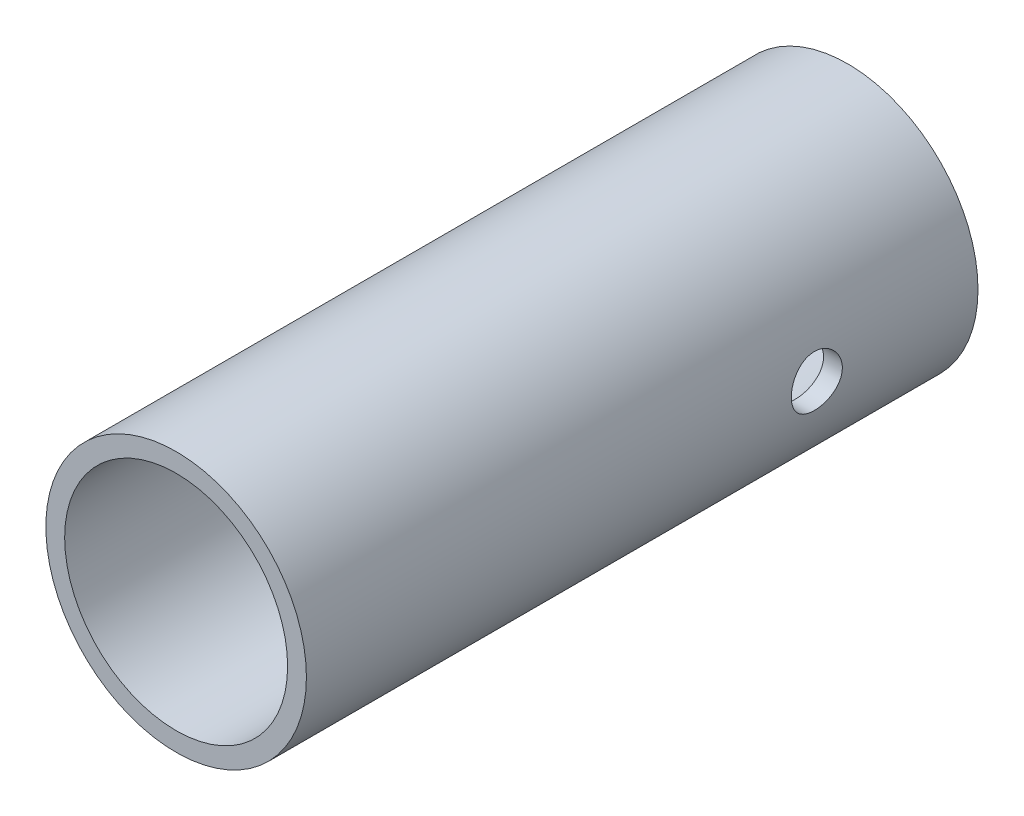
from build123d import *

# Parameters (mm, degrees)
SKETCH1_R               = 4.85
BOSS_EXTRUDE1_DEPTH     = 25
SKETCH2_R               = 4.15
CUT_EXTRUDE1_DEPTH      = 26
SKETCH3_R               = 0.95
CUT_EXTRUDE2_DEPTH      = 5.85
CUT_EXTRUDE2_DEPTH_BACK = 5.85


with BuildPart() as part:
    # Sketch1 → Boss-Extrude1 (new body)
    with BuildSketch(Plane.XY):
        Circle(SKETCH1_R)
    extrude(amount=BOSS_EXTRUDE1_DEPTH)

    # Sketch2 → Cut-Extrude1 (cut, through all)
    with BuildSketch(Plane.XY.offset(25)):
        Circle(SKETCH2_R)
    extrude(amount=-CUT_EXTRUDE1_DEPTH, mode=Mode.SUBTRACT)

    # Sketch3 → Cut-Extrude2 (cut, two sides)
    with BuildSketch(Plane(origin=(0, 0, 0), x_dir=(0, 0, -1), z_dir=(1, 0, 0))) as cut_extrude2_sk:
        with Locations((-6, 0)):
            Circle(SKETCH3_R)
    extrude(amount=CUT_EXTRUDE2_DEPTH, mode=Mode.SUBTRACT)
    extrude(cut_extrude2_sk.sketch, amount=-CUT_EXTRUDE2_DEPTH_BACK, mode=Mode.SUBTRACT)


solid = part.part
